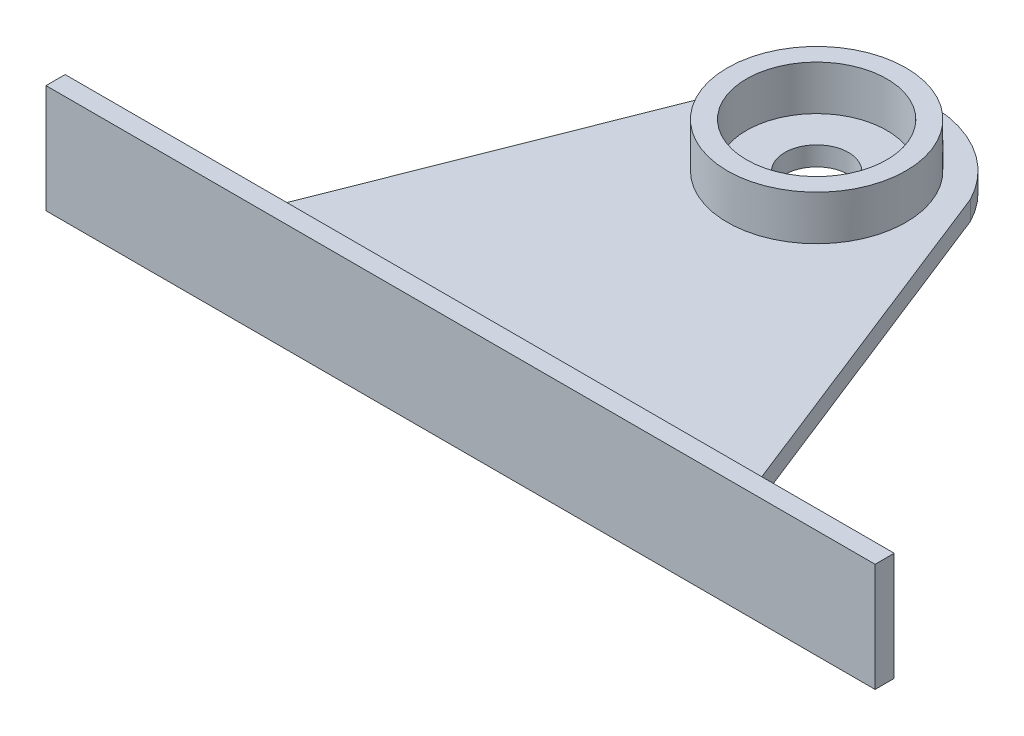
from build123d import *

# Parameters (mm, degrees)
BOSS_EXTRUDE1_DEPTH = 3
SKETCH2_R           = 14
SKETCH2_R_2         = 11
BOSS_EXTRUDE2_DEPTH = 7
SKETCH3_W           = 130
SKETCH3_H           = 17
BOSS_EXTRUDE3_DEPTH = 3
SKETCH5_R           = 5
CUT_EXTRUDE1_DEPTH  = 10


with BuildPart() as part:
    # Sketch1 → Boss-Extrude1 (new body)
    with BuildSketch(Plane(origin=(0, 0, 0), x_dir=(1, 0, 0), z_dir=(0, 1, 0))):
        with BuildLine():
            Line((-48.929144451, -17.835062273), (31.070855549, -17.835062273))
            Line((31.070855549, -17.835062273), (6.985518971, 43.196988966))
            ThreePointArc((6.985518971, 43.196988966), (-8.929144451, 52.904273338), (-24.843807874, 43.196988966))
            Line((-24.843807874, 43.196988966), (-48.929144451, -17.835062273))
        make_face()
    extrude(amount=BOSS_EXTRUDE1_DEPTH)

    # Sketch2 → Boss-Extrude2 (add)
    with BuildSketch(Plane(origin=(0, 3, 0), x_dir=(1, 0, 0), z_dir=(0, 1, 0))):
        with Locations((-8.929144451, 35.004937727)):
            Circle(SKETCH2_R)
        with Locations((-8.929144451, 35.004937727)):
            Circle(SKETCH2_R_2, mode=Mode.SUBTRACT)
    extrude(amount=BOSS_EXTRUDE2_DEPTH)

    # Sketch3 → Boss-Extrude3 (add)
    with BuildSketch(Plane.XY.offset(17.835062273)):
        with Locations((-8.929144451, 1.5)):
            Rectangle(SKETCH3_W, SKETCH3_H)
    extrude(amount=BOSS_EXTRUDE3_DEPTH)

    # Sketch5 → Cut-Extrude1 (cut)
    with BuildSketch(Plane(origin=(0, 3, 0), x_dir=(1, 0, 0), z_dir=(0, 1, 0))):
        with Locations((-8.929144451, 35.004937727)):
            Circle(SKETCH5_R)
    extrude(amount=-CUT_EXTRUDE1_DEPTH, mode=Mode.SUBTRACT)


solid = part.part
